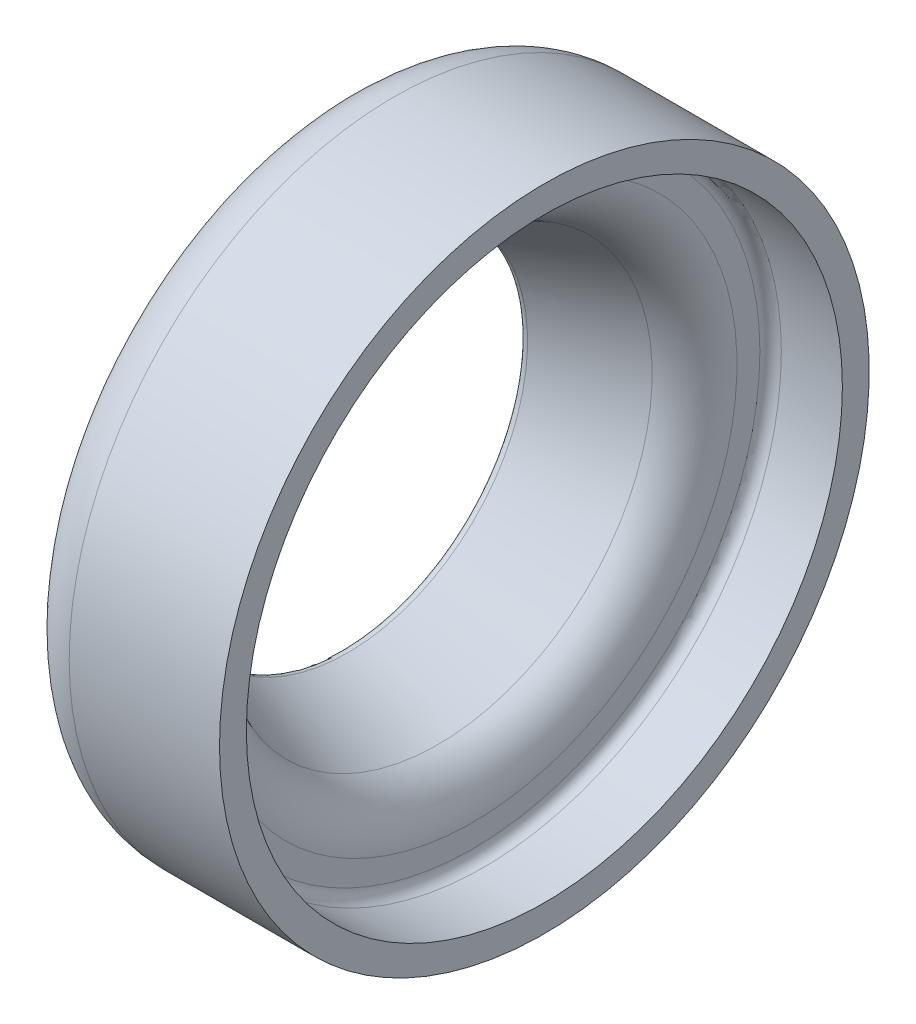
from build123d import *


with BuildPart() as part:
    # Sketch1 → Revolve1 (revolve)
    with BuildSketch(Plane.XY):
        with BuildLine():
            Line((0, 34.449404416), (0, 50.521775773))
            ThreePointArc((0, 50.521775773), (2.928932188, 57.592843585), (10, 60.521775773))
            Line((10, 60.521775773), (38, 60.521775773))
            Line((38, 60.521775773), (38, 55.521775773))
            Line((38, 55.521775773), (26.631400369, 55.521775773))
            ThreePointArc((26.631400369, 55.521775773), (25.217186807, 54.935989336), (24.631400369, 53.521775773))
            Line((24.631400369, 53.521775773), (24.631400369, 49.252739375))
            ThreePointArc((24.631400369, 49.252739375), (22.862437902, 43.573829168), (18.181396141, 39.904074764))
            Line((18.181396141, 39.904074764), (1.354999577, 33.514537955))
            ThreePointArc((1.354999577, 33.514537955), (0.432108979, 33.626300663), (0, 34.449404416))
        make_face()
        with BuildLine():
            Line((21.631400369, 55.521775773), (13, 55.521775773))
            ThreePointArc((13, 55.521775773), (5.928932188, 52.592843585), (3, 45.521775773))
            Line((3, 45.521775773), (3, 36.159847747))
            Line((3, 36.159847747), (15.067215682, 40.574682753))
            ThreePointArc((15.067215682, 40.574682753), (19.827684684, 44.236956445), (21.631400369, 49.965911274))
            Line((21.631400369, 49.965911274), (21.631400369, 55.521775773))
        make_face(mode=Mode.SUBTRACT)
    revolve(axis=Axis((0, 0, 0), (1, 0, 0)))


solid = part.part
